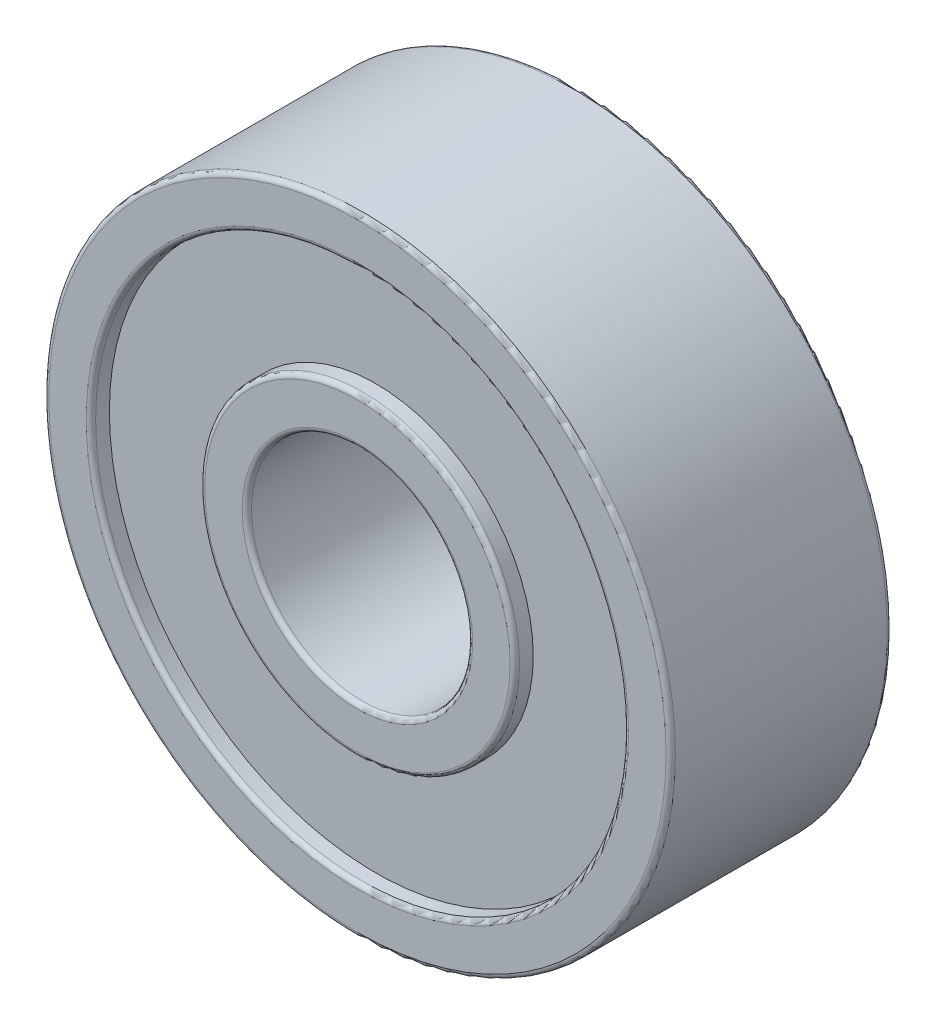
from build123d import *

# Parameters (mm, degrees)
SKETCH1_R           = 4.27
SKETCH1_R_2         = 3
BOSS_EXTRUDE1_DEPTH = 3
SKETCH2_R           = 8.5
SKETCH2_R_2         = 7.23
BOSS_EXTRUDE2_DEPTH = 3
FILLET1_R           = 0.127
FILLET2_R           = 0.127
SKETCH3_R           = 7.23
SKETCH3_R_2         = 4.27
BOSS_EXTRUDE3_DEPTH = 2.5


with BuildPart() as part:
    # Sketch1 → Boss-Extrude1 (new body, symmetric)
    with BuildSketch(Plane.XY):
        Circle(SKETCH1_R)
        Circle(SKETCH1_R_2, mode=Mode.SUBTRACT)
    extrude(amount=BOSS_EXTRUDE1_DEPTH, both=True)

    # Fillet2
    fillet2_edges = [part.edges().sort_by_distance(p)[0] for p in [
        (-4.27, 0, -3),
        (-4.27, 0, 3),
        (-3, 0, -3),
        (-3, 0, 3),
    ]]
    fillet(fillet2_edges, radius=FILLET2_R)


with BuildPart() as body_2:
    # Sketch2 → Boss-Extrude2 (new body, symmetric)
    with BuildSketch(Plane.XY):
        Circle(SKETCH2_R)
        Circle(SKETCH2_R_2, mode=Mode.SUBTRACT)
    extrude(amount=BOSS_EXTRUDE2_DEPTH, both=True)

    # Fillet1
    fillet1_edges = [body_2.edges().sort_by_distance(p)[0] for p in [
        (-8.5, 0, -3),
        (-8.5, 0, 3),
        (-7.23, 0, -3),
        (-7.23, 0, 3),
    ]]
    fillet(fillet1_edges, radius=FILLET1_R)


with BuildPart() as body_3:
    # Sketch3 → Boss-Extrude3 (new body, symmetric)
    with BuildSketch(Plane.XY):
        Circle(SKETCH3_R)
        Circle(SKETCH3_R_2, mode=Mode.SUBTRACT)
    extrude(amount=BOSS_EXTRUDE3_DEPTH, both=True)


solid = Compound([part.part, body_2.part, body_3.part])
